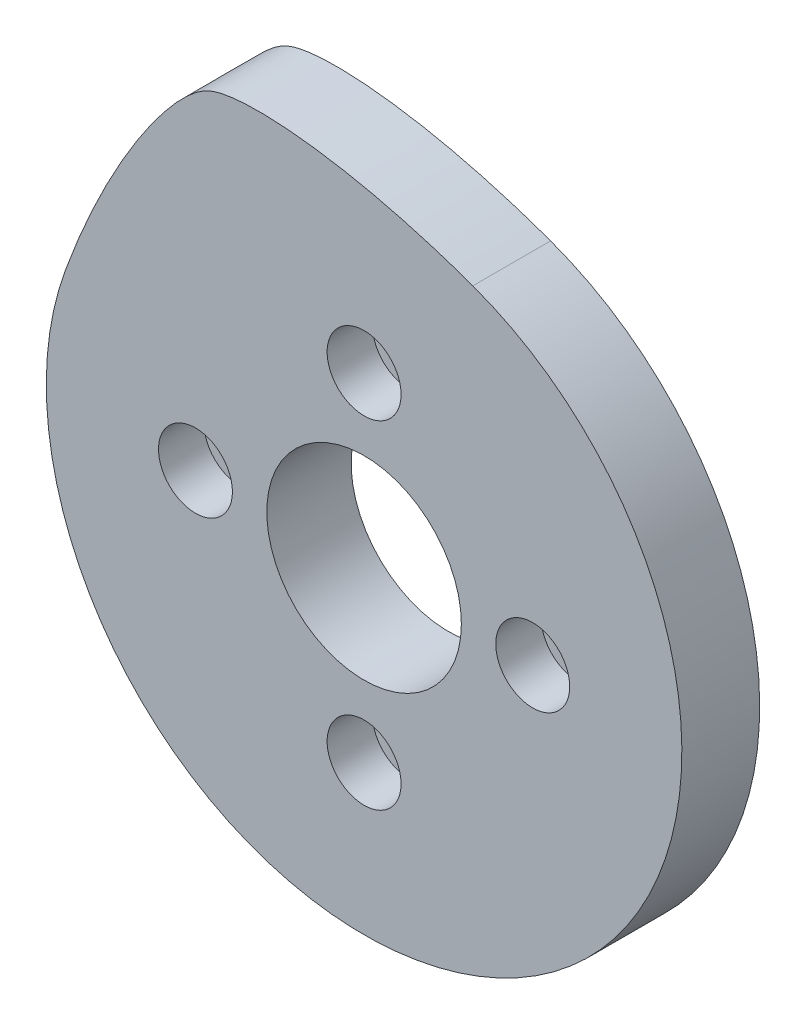
from build123d import *

# Parameters (mm, degrees)
SKETCH1_R           = 21
SKETCH1_R_2         = 2.85
BOSS_EXTRUDE1_DEPTH = 6
SKETCH2_R           = 24.5
SKETCH2_R_2         = 21
BOSS_EXTRUDE3_DEPTH = 6
SKETCH1_4_R         = 2.85
SKETCH1_4_R_2       = 1.6
BOSS_EXTRUDE2_DEPTH = 2.5
SKETCH3_R           = 21
SKETCH3_R_2         = 1.6
BOSS_EXTRUDE4_DEPTH = 0.5
SKETCH4_R           = 7.5
CUT_EXTRUDE1_DEPTH  = 7.5


with BuildPart() as part:
    # Sketch1 → Boss-Extrude1 (new body)
    with BuildSketch(Plane(origin=(0, 0, 0), x_dir=(0, 1, 0), z_dir=(0, 0, 1))):
        Circle(SKETCH1_R)
        with Locations((-13, 0)):
            Circle(SKETCH1_R_2, mode=Mode.SUBTRACT)
        with Locations((0, -13)):
            Circle(SKETCH1_R_2, mode=Mode.SUBTRACT)
        with Locations((13, 0)):
            Circle(SKETCH1_R_2, mode=Mode.SUBTRACT)
        with Locations((0, 13)):
            Circle(SKETCH1_R_2, mode=Mode.SUBTRACT)
    extrude(amount=BOSS_EXTRUDE1_DEPTH)

    # Sketch2 → Boss-Extrude3 (add)
    with BuildSketch(Plane(origin=(0, 0, 0), x_dir=(1, 0, 0), z_dir=(0, 0, -1))):
        Circle(SKETCH2_R)
        Circle(SKETCH2_R_2, mode=Mode.SUBTRACT)
        with BuildLine():
            ThreePointArc((8.379493511, -23.022469209), (-10.354147413, -22.204540782), (-23.022469209, -8.379493511))
            add(Edge.make_bspline(
                [(-23.022469209, -8.379493511), (-19.944287919, -16.836727099), (-14.723681196, -24.624750138), (-9.399453165, -27.107478442), (-0.077740076, -26.100650499), (8.379493511, -23.022469209)],
                knots=[0, 0, 0, 0, 0.45, 0.55, 1, 1, 1, 1], degree=3))
        make_face()
    extrude(amount=-BOSS_EXTRUDE3_DEPTH)

    # Sketch1_4 → Boss-Extrude2 (add)
    with BuildSketch(Plane(origin=(0, 0, 0), x_dir=(0, 1, 0), z_dir=(0, 0, 1))):
        with Locations((-13, 0)):
            Circle(SKETCH1_4_R)
        with Locations((-13, 0)):
            Circle(SKETCH1_4_R_2, mode=Mode.SUBTRACT)
        with Locations((0, 13)):
            Circle(SKETCH1_4_R)
        with Locations((0, 13)):
            Circle(SKETCH1_4_R_2, mode=Mode.SUBTRACT)
        with Locations((13, 0)):
            Circle(SKETCH1_4_R)
        with Locations((13, 0)):
            Circle(SKETCH1_4_R_2, mode=Mode.SUBTRACT)
        with Locations((0, -13)):
            Circle(SKETCH1_4_R)
        with Locations((0, -13)):
            Circle(SKETCH1_4_R_2, mode=Mode.SUBTRACT)
    extrude(amount=BOSS_EXTRUDE2_DEPTH)

    # Sketch3 → Boss-Extrude4 (add)
    with BuildSketch(Plane(origin=(0, 0, 0), x_dir=(1, 0, 0), z_dir=(0, 0, -1))):
        Circle(SKETCH3_R)
        with Locations((13, 0)):
            Circle(SKETCH3_R_2, mode=Mode.SUBTRACT)
        with Locations((0, 13)):
            Circle(SKETCH3_R_2, mode=Mode.SUBTRACT)
        with Locations((-13, 0)):
            Circle(SKETCH3_R_2, mode=Mode.SUBTRACT)
        with Locations((0, -13)):
            Circle(SKETCH3_R_2, mode=Mode.SUBTRACT)
    extrude(amount=BOSS_EXTRUDE4_DEPTH)

    # Sketch4 → Cut-Extrude1 (cut, through all)
    with BuildSketch(Plane.XY.offset(6)):
        Circle(SKETCH4_R)
    extrude(amount=-CUT_EXTRUDE1_DEPTH, mode=Mode.SUBTRACT)


solid = part.part
